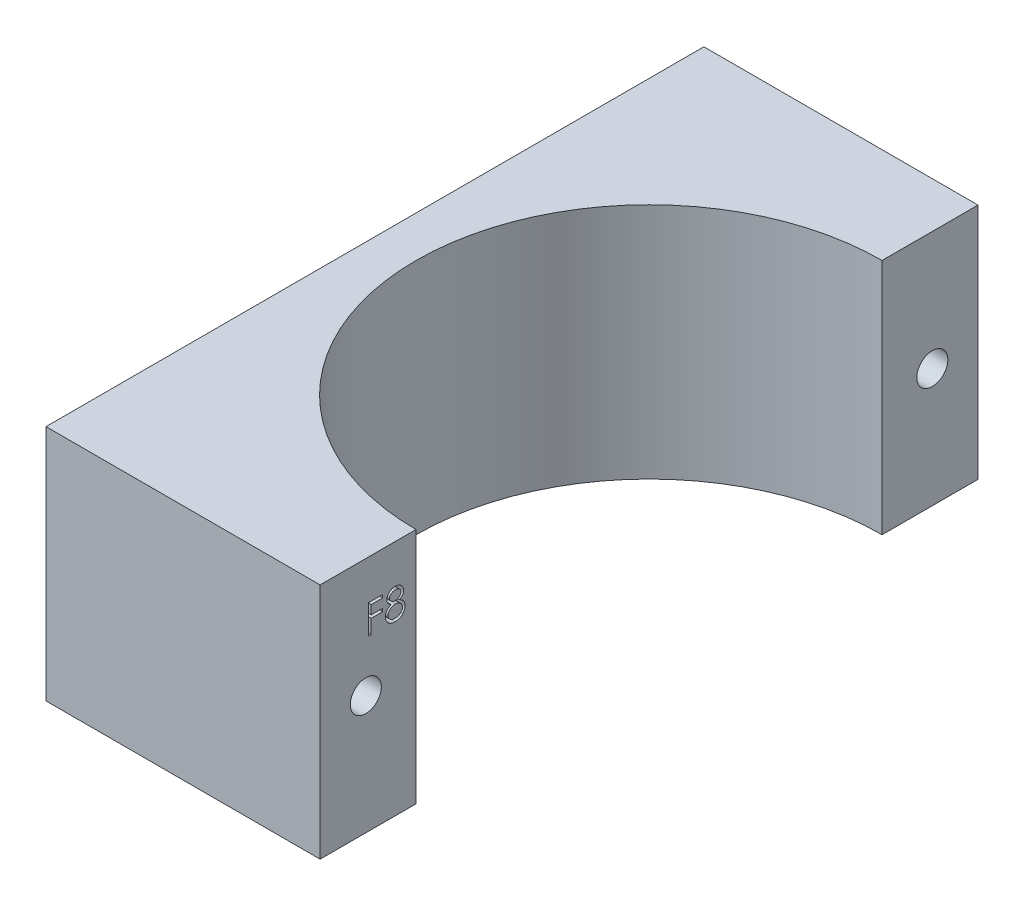
from build123d import *

# Parameters (mm, degrees)
BOSS_EXTRUDE1_DEPTH = 26
SKETCH2_R           = 1.7
CUT_EXTRUDE1_DEPTH  = 31
CUT_EXTRUDE2_DEPTH  = 1


with BuildPart() as part:
    # Sketch1 → Boss-Extrude1 (new body)
    with BuildSketch(Plane(origin=(0, 0, 0), x_dir=(1, 0, 0), z_dir=(0, 1, 0))):
        with BuildLine():
            Line((-46.998275301, 32.528571429), (-46.998275301, -39.471428571))
            Line((-46.998275301, -39.471428571), (-16.998275301, -39.471428571))
            Line((-16.998275301, -39.471428571), (-16.998275301, -28.971428571))
            ThreePointArc((-16.998275301, -28.971428571), (-42.498275301, -3.471428571), (-16.998275301, 22.028571429))
            Line((-16.998275301, 22.028571429), (-16.998275301, 32.528571429))
            Line((-16.998275301, 32.528571429), (-46.998275301, 32.528571429))
        make_face()
    extrude(amount=BOSS_EXTRUDE1_DEPTH)

    # Sketch2 → Cut-Extrude1 (cut, through all)
    with BuildSketch(Plane(origin=(-16.998275301, 0, 0), x_dir=(0, 0, -1), z_dir=(1, 0, 0))):
        with Locations((-34.471428571, 13)):
            Circle(SKETCH2_R)
        with Locations((27.528571429, 13)):
            Circle(SKETCH2_R)
    extrude(amount=-CUT_EXTRUDE1_DEPTH, mode=Mode.SUBTRACT)

    # Sketch3 → Cut-Extrude2 (cut)
    with BuildSketch(Plane(origin=(-16.998275301, 0, 0), x_dir=(0, 0, -1), z_dir=(1, 0, 0))):
        Polygon((-34.164231178, 21.664809495), (-32.617436306, 21.664809495), (-32.617436306, 21.33916847), (-33.87929528, 21.33916847), (-33.87929528, 20.362245393), (-32.617436306, 20.362245393), (-32.617436306, 20.036604367), (-33.87929528, 20.036604367), (-33.87929528, 18.489809495), (-34.164231178, 18.489809495), align=None)
        with BuildLine():
            add(Edge.make_bspline(
                [(-30.788885625, 20.258574519), (-30.7628973, 20.245023659), (-30.712211387, 20.218594957), (-30.640023491, 20.176040134), (-30.574051526, 20.131190116), (-30.512465088, 20.086163301), (-30.456346191, 20.039235303), (-30.406322331, 19.990219511), (-30.361157847, 19.940339404), (-30.32176355, 19.888750334), (-30.287113562, 19.83558936), (-30.25716684, 19.780716948), (-30.231569806, 19.724253352), (-30.211283425, 19.665582228), (-30.194572229, 19.605565419), (-30.183073644, 19.543427964), (-30.176889726, 19.479579312), (-30.175720588, 19.436428067), (-30.175128614, 19.414579127)],
                knots=[0, 0, 0, 0, 8.792e-05, 0.000171474, 0.000251207, 0.000327149, 0.000400277, 0.000470441, 0.000537099, 0.000601976, 0.000664954, 0.000727287, 0.000789347, 0.000850699, 0.000913343, 0.00097609, 0.001040009, 0.001105568, 0.001105568, 0.001105568, 0.001105568], degree=3))
            add(Edge.make_bspline(
                [(-30.175128614, 19.414579127), (-30.175828402, 19.384010469), (-30.177213547, 19.323503626), (-30.189278532, 19.23419894), (-30.207342448, 19.147465394), (-30.23372172, 19.063322006), (-30.267933153, 18.982233075), (-30.310094283, 18.904129188), (-30.357820162, 18.827730243), (-30.396148979, 18.780722643), (-30.415543277, 18.756936899)],
                knots=[0, 0, 0, 0, 9.1666e-05, 0.000181441, 0.000269884, 0.000357188, 0.000445547, 0.000533467, 0.000623271, 0.000715257, 0.000715257, 0.000715257, 0.000715257], degree=3))
            add(Edge.make_bspline(
                [(-30.415543277, 18.756936899), (-30.440794936, 18.729183975), (-30.490986212, 18.674021079), (-30.576967868, 18.602401415), (-30.671330577, 18.542213036), (-30.773709207, 18.493162103), (-30.883830092, 18.454984217), (-31.001669767, 18.427549933), (-31.127457963, 18.411836015), (-31.213913641, 18.409564539), (-31.258266635, 18.408399239)],
                knots=[0, 0, 0, 0, 0.000112465, 0.000223541, 0.000334517, 0.000447451, 0.000563311, 0.000683491, 0.000809791, 0.000942842, 0.000942842, 0.000942842, 0.000942842], degree=3))
            add(Edge.make_bspline(
                [(-31.258266635, 18.408399239), (-31.300914494, 18.409444701), (-31.383902897, 18.411479064), (-31.504696115, 18.425262584), (-31.617293471, 18.449417863), (-31.722349657, 18.48247833), (-31.819231328, 18.52548618), (-31.907662427, 18.579015237), (-31.988918816, 18.640910902), (-32.060534546, 18.712950816), (-32.124114777, 18.790110457), (-32.179965797, 18.869713703), (-32.226387997, 18.951767821), (-32.265691862, 19.035049311), (-32.295779996, 19.120725465), (-32.316619073, 19.208355477), (-32.329853665, 19.297786285), (-32.331614552, 19.358139999), (-32.332500409, 19.388502404)],
                knots=[0, 0, 0, 0, 0.000127941, 0.00024896, 0.0003641, 0.000472919, 0.000578826, 0.000681249, 0.000782384, 0.000884474, 0.000985208, 0.001082071, 0.00117579, 0.001267699, 0.001358015, 0.001447642, 0.001537588, 0.001628648, 0.001628648, 0.001628648, 0.001628648], degree=3))
            add(Edge.make_bspline(
                [(-32.332500409, 19.388502404), (-32.331976188, 19.4107811), (-32.330940143, 19.454811666), (-32.323769316, 19.519862271), (-32.312240926, 19.583177336), (-32.296584133, 19.644990725), (-32.275365131, 19.704852422), (-32.249745482, 19.763046066), (-32.219871496, 19.819637356), (-32.185326439, 19.874935769), (-32.145138175, 19.92816647), (-32.099632578, 19.980232836), (-32.047900154, 20.030326958), (-31.990516421, 20.079060872), (-31.92813716, 20.127299077), (-31.859142114, 20.172434631), (-31.785360314, 20.217662928), (-31.732922554, 20.244703337), (-31.706023045, 20.258574519)],
                knots=[0, 0, 0, 0, 6.683e-05, 0.00013208, 0.000196078, 0.000259788, 0.000323151, 0.000386373, 0.000450387, 0.000514973, 0.000581755, 0.000650262, 0.000722225, 0.000797558, 0.000876046, 0.000958601, 0.001044771, 0.001135535, 0.001135535, 0.001135535, 0.001135535], degree=3))
            add(Edge.make_bspline(
                [(-31.706023045, 20.258574519), (-31.74284522, 20.278653917), (-31.814143259, 20.31753325), (-31.908549109, 20.388967853), (-31.989639175, 20.466336085), (-32.055184526, 20.551271684), (-32.106775761, 20.641121349), (-32.142171209, 20.735322921), (-32.166116591, 20.832129681), (-32.168488613, 20.898266016), (-32.169679896, 20.93148117)],
                knots=[0, 0, 0, 0, 0.000125671, 0.000243334, 0.000353983, 0.000460974, 0.000564081, 0.000663536, 0.000762121, 0.000861586, 0.000861586, 0.000861586, 0.000861586], degree=3))
            add(Edge.make_bspline(
                [(-32.169679896, 20.93148117), (-32.168196332, 20.965315384), (-32.165214112, 21.033328054), (-32.141099242, 21.134570751), (-32.101801753, 21.234008635), (-32.048351992, 21.331159746), (-31.981779303, 21.422736012), (-31.901908508, 21.504869585), (-31.810646945, 21.57681643), (-31.708450166, 21.63721053), (-31.598471581, 21.686362849), (-31.482433746, 21.720270418), (-31.362358427, 21.742437467), (-31.280626924, 21.744947218), (-31.239186106, 21.746219752)],
                knots=[0, 0, 0, 0, 0.000101414, 0.000203861, 0.000310395, 0.000421407, 0.000535644, 0.000648991, 0.000764017, 0.000883238, 0.001004257, 0.00112439, 0.001245163, 0.001369384, 0.001369384, 0.001369384, 0.001369384], degree=3))
            add(Edge.make_bspline(
                [(-31.239186106, 21.746219752), (-31.198814788, 21.744907712), (-31.119207148, 21.742320519), (-31.002190593, 21.720742422), (-30.890226597, 21.684702072), (-30.783701266, 21.635809591), (-30.684521643, 21.575587152), (-30.596889549, 21.502652073), (-30.519480706, 21.42088081), (-30.455450577, 21.329332312), (-30.402688528, 21.232554508), (-30.365948424, 21.131296935), (-30.342406277, 21.027747432), (-30.339436868, 20.957681529), (-30.337949127, 20.922576923)],
                knots=[0, 0, 0, 0, 0.000121046, 0.000238688, 0.000355551, 0.000473091, 0.000589591, 0.000702541, 0.000814133, 0.000926368, 0.001036773, 0.001143821, 0.001248612, 0.001353832, 0.001353832, 0.001353832, 0.001353832], degree=3))
            add(Edge.make_bspline(
                [(-30.337949127, 20.922576923), (-30.339250478, 20.888126664), (-30.341806258, 20.820468313), (-30.363305489, 20.721837826), (-30.399512566, 20.629470691), (-30.448946557, 20.542318799), (-30.513376821, 20.461962726), (-30.591943314, 20.387380642), (-30.684019655, 20.317959877), (-30.753199173, 20.278783675), (-30.788885625, 20.258574519)],
                knots=[0, 0, 0, 0, 0.000103272, 0.000202821, 0.000301089, 0.000399936, 0.000502246, 0.000608856, 0.00072423, 0.000847159, 0.000847159, 0.000847159, 0.000847159], degree=3))
        make_face()
        with BuildLine():
            add(Edge.make_bspline(
                [(-31.255086546, 21.420578726), (-31.277357635, 21.419987777), (-31.320929621, 21.418831621), (-31.384818487, 21.412791286), (-31.445571992, 21.401040868), (-31.503824897, 21.385402893), (-31.558778533, 21.364277361), (-31.611179236, 21.339426174), (-31.660135187, 21.309212815), (-31.706237369, 21.275320871), (-31.747739857, 21.238043735), (-31.784573986, 21.199205576), (-31.815170204, 21.158043613), (-31.841151782, 21.115581744), (-31.860003587, 21.070559721), (-31.874122634, 21.024357868), (-31.88366704, 20.976392341), (-31.884382222, 20.943611364), (-31.884743998, 20.927029047)],
                knots=[0, 0, 0, 0, 6.683e-05, 0.000130749, 0.000192246, 0.000252268, 0.000311448, 0.000368626, 0.000426002, 0.000483754, 0.000540058, 0.000593157, 0.000644039, 0.000693668, 0.000742106, 0.000789989, 0.000838515, 0.000888189, 0.000888189, 0.000888189, 0.000888189], degree=3))
            add(Edge.make_bspline(
                [(-31.884743998, 20.927029047), (-31.884120458, 20.910446013), (-31.882888254, 20.877675556), (-31.873358602, 20.829283235), (-31.859155598, 20.781729322), (-31.836793926, 20.736144567), (-31.809973016, 20.690947662), (-31.776870034, 20.647268202), (-31.737419273, 20.604954174), (-31.692944381, 20.564365481), (-31.644492486, 20.526357318), (-31.593162675, 20.493361646), (-31.539599163, 20.46575356), (-31.484352286, 20.442776171), (-31.42685898, 20.424914585), (-31.367471536, 20.412243027), (-31.306179973, 20.404367216), (-31.264650446, 20.40342649), (-31.243638229, 20.402950521)],
                knots=[0, 0, 0, 0, 4.9711e-05, 9.8236e-05, 0.000147523, 0.000198165, 0.000250085, 0.000305037, 0.000362198, 0.000423421, 0.000485507, 0.000546726, 0.00060618, 0.000666063, 0.000726011, 0.000786513, 0.000848046, 0.000911063, 0.000911063, 0.000911063, 0.000911063], degree=3))
            add(Edge.make_bspline(
                [(-31.243638229, 20.402950521), (-31.216650635, 20.403742336), (-31.162942001, 20.405318146), (-31.083767179, 20.419969568), (-31.006784637, 20.443016365), (-30.932817203, 20.47454862), (-30.863779472, 20.514125321), (-30.802238839, 20.56150813), (-30.748720229, 20.615602961), (-30.703779818, 20.675567677), (-30.6689366, 20.739386618), (-30.641811389, 20.803431169), (-30.625971572, 20.868384621), (-30.623905493, 20.91189751), (-30.622885024, 20.933389223)],
                knots=[0, 0, 0, 0, 8.0897e-05, 0.000160995, 0.000240677, 0.000321602, 0.000401674, 0.000478766, 0.000553873, 0.000629305, 0.000702756, 0.000771496, 0.000837522, 0.000901961, 0.000901961, 0.000901961, 0.000901961], degree=3))
            add(Edge.make_bspline(
                [(-30.622885024, 20.933389223), (-30.623367531, 20.948473227), (-30.624325238, 20.978412813), (-30.632217432, 21.022625473), (-30.645258366, 21.065832309), (-30.66291416, 21.108390255), (-30.686145903, 21.149702205), (-30.713690559, 21.190417577), (-30.747150071, 21.229620449), (-30.784702549, 21.268224411), (-30.827288742, 21.303951347), (-30.874826576, 21.335369976), (-30.927072336, 21.362051186), (-30.984027254, 21.383721699), (-31.045481578, 21.399997973), (-31.111152257, 21.41218666), (-31.181586863, 21.419056554), (-31.23005528, 21.420060331), (-31.255086546, 21.420578726)],
                knots=[0, 0, 0, 0, 4.5229e-05, 8.9773e-05, 0.000134244, 0.000180429, 0.000227687, 0.0002762, 0.000327666, 0.000382086, 0.000437623, 0.000494072, 0.000552668, 0.000613264, 0.000676521, 0.000743136, 0.000813447, 0.00088854, 0.00088854, 0.00088854, 0.00088854], degree=3))
        make_face(mode=Mode.SUBTRACT)
        with BuildLine():
            add(Edge.make_bspline(
                [(-31.236642035, 20.077309495), (-31.264877569, 20.076807264), (-31.320268797, 20.075822007), (-31.401419011, 20.064855103), (-31.479300097, 20.04958844), (-31.553649468, 20.026428322), (-31.624435727, 19.996314363), (-31.692042075, 19.96008803), (-31.755951314, 19.91726595), (-31.81528093, 19.868392163), (-31.869458521, 19.815723944), (-31.916991265, 19.759969007), (-31.957356873, 19.702163566), (-31.98986275, 19.641573473), (-32.016543393, 19.579481711), (-32.034063839, 19.514341964), (-32.04529582, 19.447406512), (-32.046804064, 19.401904137), (-32.047564511, 19.37896214)],
                knots=[0, 0, 0, 0, 8.465e-05, 0.000166063, 0.000245269, 0.000322519, 0.000399185, 0.000475732, 0.000552289, 0.000629573, 0.000706032, 0.000778675, 0.000849069, 0.000917087, 0.000984652, 0.001051313, 0.001118964, 0.00118776, 0.00118776, 0.00118776, 0.00118776], degree=3))
            add(Edge.make_bspline(
                [(-32.047564511, 19.37896214), (-32.046327841, 19.350449818), (-32.043874315, 19.293882037), (-32.024410079, 19.210276965), (-31.993172129, 19.129340723), (-31.949606397, 19.05173288), (-31.895660813, 18.979206712), (-31.82932466, 18.915989037), (-31.754720472, 18.85981741), (-31.66932399, 18.814387212), (-31.576043881, 18.778106165), (-31.474904956, 18.75310897), (-31.367358708, 18.736561369), (-31.293100364, 18.734893876), (-31.255086546, 18.734040265)],
                knots=[0, 0, 0, 0, 8.5463e-05, 0.000169557, 0.000256135, 0.000344968, 0.000435792, 0.000526198, 0.000618931, 0.000715121, 0.000815398, 0.000918443, 0.001027099, 0.00114106, 0.00114106, 0.00114106, 0.00114106], degree=3))
            add(Edge.make_bspline(
                [(-31.255086546, 18.734040265), (-31.225377284, 18.734610684), (-31.167494114, 18.735722043), (-31.08305186, 18.745532153), (-31.003364306, 18.761089312), (-30.928585981, 18.783716672), (-30.857879784, 18.81133915), (-30.792444527, 18.846873824), (-30.730596863, 18.887289146), (-30.675384409, 18.935239045), (-30.625098569, 18.986474015), (-30.581253368, 19.040712126), (-30.543191876, 19.096479307), (-30.513318794, 19.155035818), (-30.489437121, 19.215258233), (-30.472270754, 19.277701876), (-30.461678758, 19.342558265), (-30.460607517, 19.386553851), (-30.460064511, 19.408854968)],
                knots=[0, 0, 0, 0, 8.9099e-05, 0.000173594, 0.000254671, 0.000332343, 0.000407694, 0.000481959, 0.000555341, 0.00062888, 0.000700843, 0.000770474, 0.000837859, 0.000903001, 0.000967251, 0.001031903, 0.001096942, 0.001163799, 0.001163799, 0.001163799, 0.001163799], degree=3))
            add(Edge.make_bspline(
                [(-30.460064511, 19.408854968), (-30.460886245, 19.430515127), (-30.462506561, 19.473225177), (-30.47279056, 19.536513383), (-30.490857105, 19.597657365), (-30.515646958, 19.657392727), (-30.548649689, 19.714509118), (-30.587516106, 19.770494502), (-30.634410057, 19.823794991), (-30.687398626, 19.874824585), (-30.745146398, 19.92201029), (-30.806530165, 19.963751959), (-30.871077427, 19.998905664), (-30.938651597, 20.027495628), (-31.00910263, 20.049981404), (-31.082378707, 20.065689485), (-31.158565622, 20.075576982), (-31.21032254, 20.076725467), (-31.236642035, 20.077309495)],
                knots=[0, 0, 0, 0, 6.4986e-05, 0.000128141, 0.000191743, 0.000255883, 0.000321676, 0.000389256, 0.000460037, 0.000534255, 0.000609748, 0.000683485, 0.00075663, 0.000829872, 0.00090329, 0.00097814, 0.001054425, 0.001133355, 0.001133355, 0.001133355, 0.001133355], degree=3))
        make_face(mode=Mode.SUBTRACT)
    extrude(amount=-CUT_EXTRUDE2_DEPTH, mode=Mode.SUBTRACT)


solid = part.part
